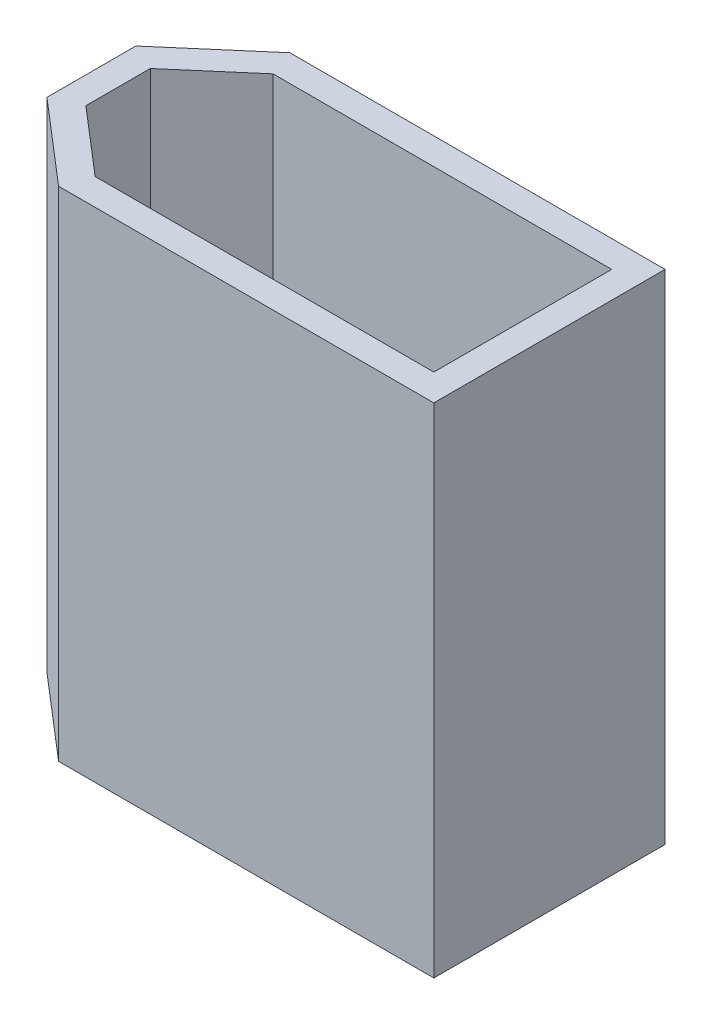
from build123d import *

# Parameters (mm, degrees)
BOSS_EXTRUDE1_DEPTH = 11.2


with BuildPart() as part:
    # Sketch1 → Boss-Extrude1 (new body)
    with BuildSketch(Plane(origin=(0, 0, 0), x_dir=(1, 0, 0), z_dir=(0, 1, 0))):
        Polygon((-3.288061159, 2.6), (-5.15, 1), (-5.15, -1), (-3.288061159, -2.6), (5.15, -2.6), (5.15, 2.6), align=None)
        Polygon((4.55, 2), (-3.065679168, 2), (-4.55, 0.724494447), (-4.55, -0.724494447), (-3.065679168, -2), (4.55, -2), align=None, mode=Mode.SUBTRACT)
    extrude(amount=BOSS_EXTRUDE1_DEPTH)


solid = part.part
